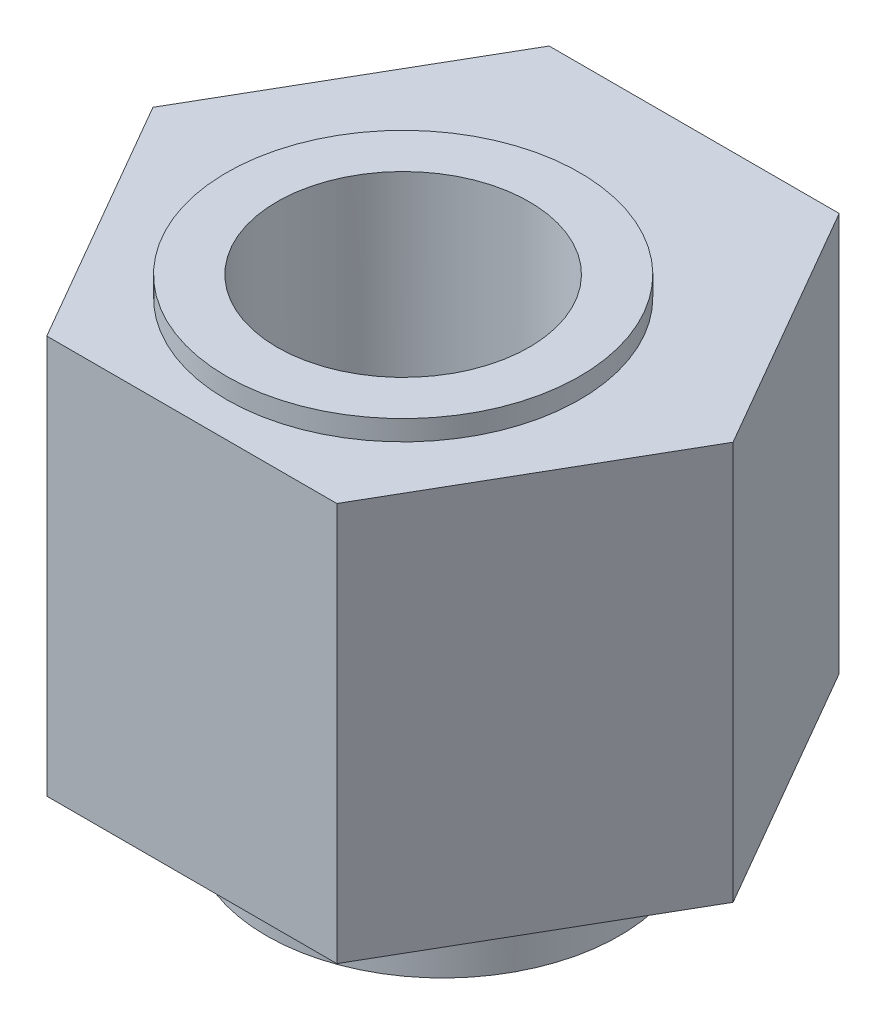
from build123d import *

# Parameters (mm, degrees)
BOSS_EXTRUDE1_DEPTH = 7.9
SKETCH4_R           = 2.5
CUT_EXTRUDE1_DEPTH  = 8.9
SKETCH_1_R          = 3.5
SKETCH_1_R_2        = 2.5
EXTRUDE_1_DEPTH     = 0.4
SKETCH_2_R          = 3.5
SKETCH_2_R_2        = 2.5
EXTRUDE_2_DEPTH     = 1.7


with BuildPart() as part:
    # Sketch1 → Boss-Extrude1 (new body)
    with BuildSketch(Plane(origin=(0, 0, 0), x_dir=(1, 0, 0), z_dir=(0, 1, 0))):
        Polygon((5.750408681, 0), (2.875204341, 4.98), (-2.875204341, 4.98), (-5.750408681, 0), (-2.875204341, -4.98), (2.875204341, -4.98), align=None)
    extrude(amount=BOSS_EXTRUDE1_DEPTH)

    # Sketch4 → Cut-Extrude1 (cut, through all)
    with BuildSketch(Plane(origin=(0, 7.9, 0), x_dir=(1, 0, 0), z_dir=(0, 1, 0))):
        with Locations((0, -0.79)):
            Circle(SKETCH4_R)
    extrude(amount=-CUT_EXTRUDE1_DEPTH, mode=Mode.SUBTRACT)

    # 草图1 → 凸台-拉伸1 (add)
    with BuildSketch(Plane(origin=(0, 7.9, 0), x_dir=(1, 0, 0), z_dir=(0, 1, 0))):
        with Locations((0, -0.79)):
            Circle(SKETCH_1_R)
        with Locations((0, -0.79)):
            Circle(SKETCH_1_R_2, mode=Mode.SUBTRACT)
    extrude(amount=EXTRUDE_1_DEPTH)

    # 草图2 → 凸台-拉伸2 (add)
    with BuildSketch(Plane.XZ):
        Circle(SKETCH_2_R)
        with Locations((0, 0.79)):
            Circle(SKETCH_2_R_2, mode=Mode.SUBTRACT)
    extrude(amount=EXTRUDE_2_DEPTH)


solid = part.part
